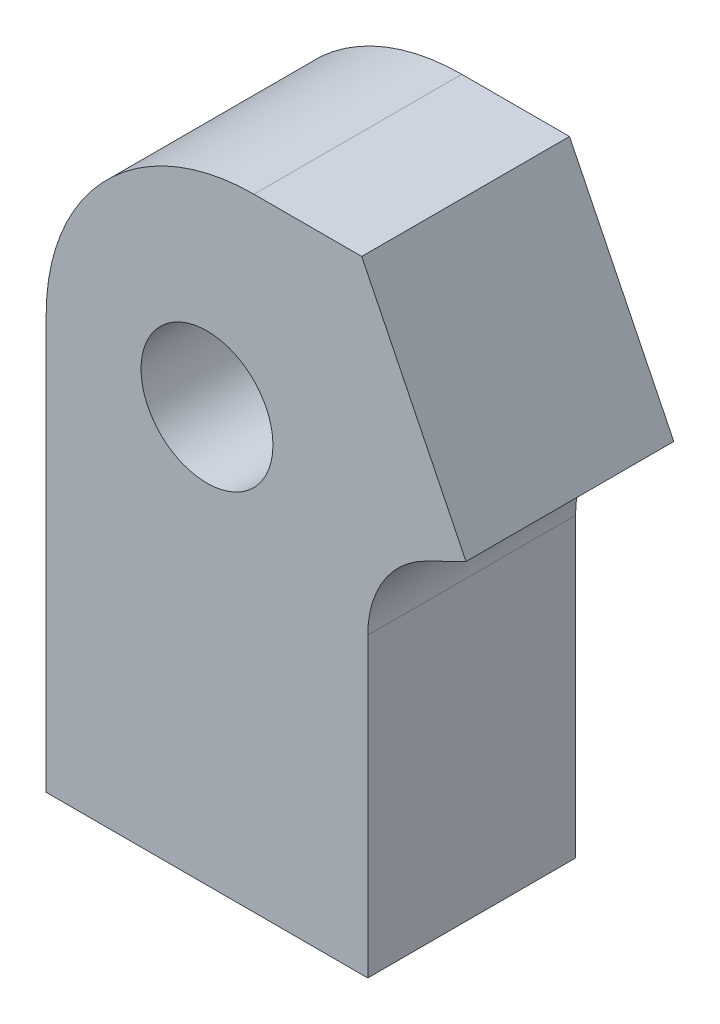
from build123d import *

# Parameters (mm, degrees)
SKETCH1_R           = 3.175
BOSS_EXTRUDE1_DEPTH = 10


with BuildPart() as part:
    # Sketch1 → Boss-Extrude1 (new body)
    with BuildSketch(Plane.XY):
        with BuildLine():
            Line((-47.46444948, 0), (-47.46444948, 19.93))
            ThreePointArc((-47.46444948, 19.93), (-44.535517292, 27.001067812), (-37.46444948, 29.93))
            Line((-37.46444948, 29.93), (-32.278753178, 29.93))
            Line((-32.278753178, 29.93), (-29.769076862, 24.828075765))
            Line((-29.769076862, 24.828075765), (-27.259400546, 19.72615153))
            Line((-27.259400546, 19.72615153), (-29.195289257, 18.773872777))
            ThreePointArc((-29.195289257, 18.773872777), (-31.233008862, 16.929762135), (-31.988313386, 14.287308668))
            Line((-31.988313386, 14.287308668), (-31.988313386, 0))
            Line((-31.988313386, 0), (-47.46444948, 0))
        make_face()
        with Locations((-39.726381433, 19.93)):
            Circle(SKETCH1_R, mode=Mode.SUBTRACT)
    extrude(amount=BOSS_EXTRUDE1_DEPTH)


solid = part.part
